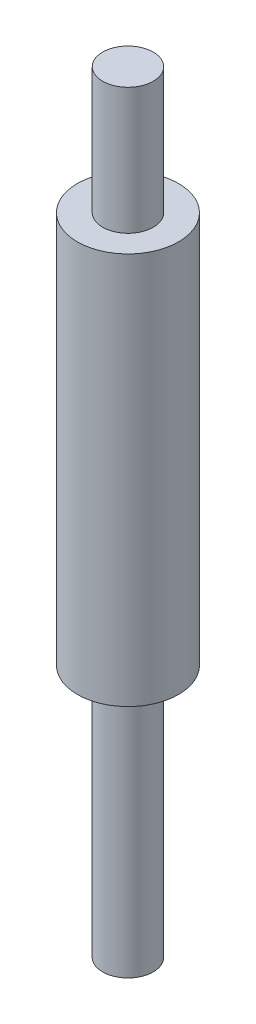
from build123d import *

# Parameters (mm, degrees)
SKETCH1_R                = 4
BOSS_EXTRUDE1_DEPTH      = 31
BOSS_EXTRUDE2_DEPTH      = 41
BOSS_EXTRUDE2_DEPTH_BACK = 20
SKETCH1_4_R              = 2


with BuildPart() as part:
    # Sketch1 → Boss-Extrude1 (new body)
    with BuildSketch(Plane(origin=(0, 0, 0), x_dir=(1, 0, 0), z_dir=(0, 1, 0))):
        Circle(SKETCH1_R)
    extrude(amount=BOSS_EXTRUDE1_DEPTH)

    # Sketch1_4 → Boss-Extrude2 (add, two sides: drawn at the far end of the back side and taken through both)
    with BuildSketch(Plane(origin=(0, 0, 0), x_dir=(1, 0, 0), z_dir=(0, 1, 0)).offset(-BOSS_EXTRUDE2_DEPTH_BACK)):
        Circle(SKETCH1_4_R)
    extrude(amount=BOSS_EXTRUDE2_DEPTH + BOSS_EXTRUDE2_DEPTH_BACK)


solid = part.part
